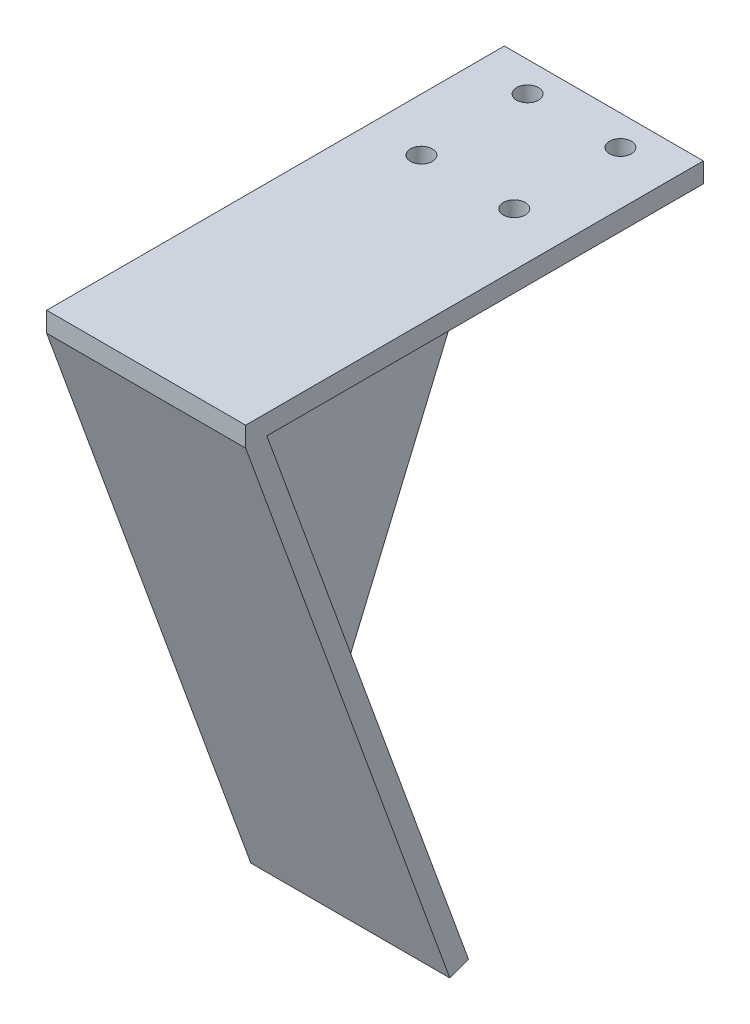
from build123d import *

# Parameters (mm, degrees)
BOSS_EXTRUDE1_DEPTH = 3
SKETCH2_R           = 1.65
CUT_EXTRUDE1_DEPTH  = 4
SKETCH3_W           = 30
SKETCH3_H           = 3
BOSS_EXTRUDE2_DEPTH = 8
BOSS_EXTRUDE3_DEPTH = 30
BOSS_EXTRUDE4_DEPTH = 3


with BuildPart() as part:
    # Sketch1 → Boss-Extrude1 (new body)
    with BuildSketch(Plane(origin=(0, 0, 0), x_dir=(1, 0, 0), z_dir=(0, 1, 0))):
        Polygon((15, -28), (15, 30), (-15, 30), (-15, -28), (-15, -31), (15, -31), align=None)
    extrude(amount=BOSS_EXTRUDE1_DEPTH)

    # Sketch2 → Cut-Extrude1 (cut)
    with BuildSketch(Plane(origin=(0, 3, 0), x_dir=(1, 0, 0), z_dir=(0, 1, 0))):
        with Locations((-7, 25.5)):
            Circle(SKETCH2_R)
        with Locations((7, 25.5)):
            Circle(SKETCH2_R)
        with Locations((-7, 9.5)):
            Circle(SKETCH2_R)
        with Locations((7, 9.5)):
            Circle(SKETCH2_R)
    extrude(amount=-CUT_EXTRUDE1_DEPTH, mode=Mode.SUBTRACT)

    # Sketch3 → Boss-Extrude2 (add)
    with BuildSketch(Plane.XY.offset(31)):
        with Locations((0, 1.5)):
            Rectangle(SKETCH3_W, SKETCH3_H)
    extrude(amount=BOSS_EXTRUDE2_DEPTH)

    # Sketch5 → Boss-Extrude3 (add)
    with BuildSketch(Plane.ZY.offset(15)):
        Polygon((39, 0), (8.218187101, -84.572335871), (5.399109238, -83.546275441), (35.807466683, 0), align=None)
    extrude(amount=-BOSS_EXTRUDE3_DEPTH)

    # Sketch6 → Boss-Extrude4 (add)
    with BuildSketch(Plane.ZY.offset(15)):
        Polygon((5.399109238, -83.546275441), (-30, 0), (-30, 3), (39, 3), (39, 0), (8.218187101, -84.572335871), align=None)
    extrude(amount=-BOSS_EXTRUDE4_DEPTH)


solid = part.part
